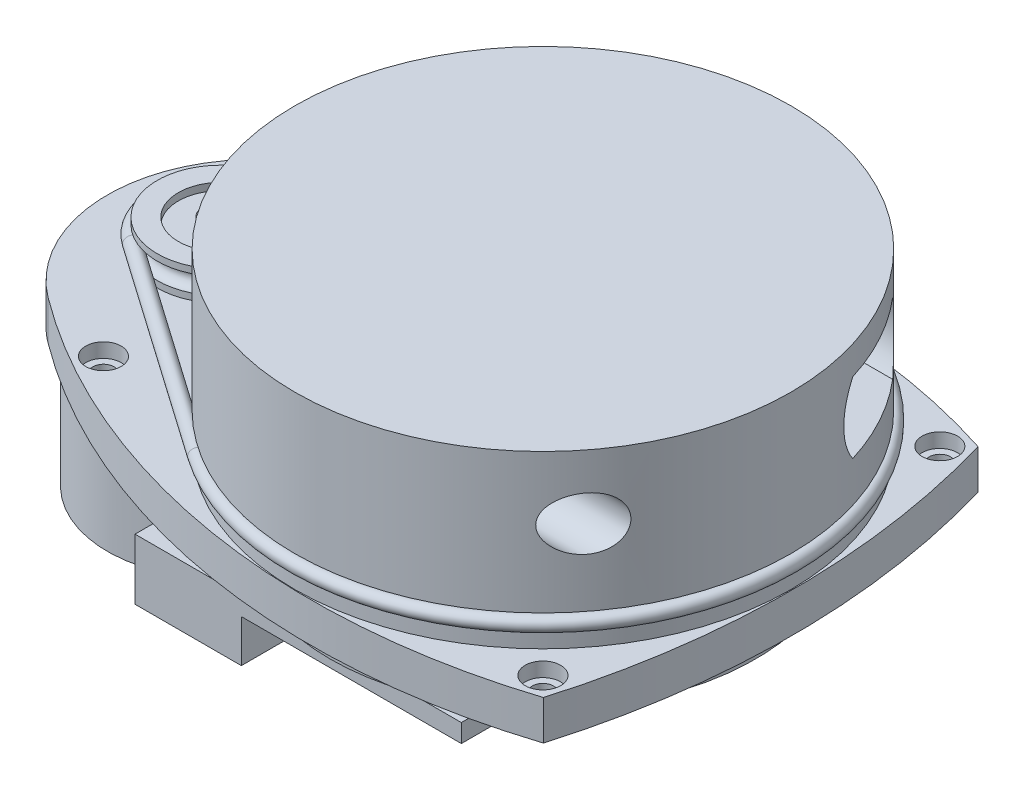
from build123d import *

# Parameters (mm, degrees)
SKETCH1_R           = 1.5
BOSS_EXTRUDE1_DEPTH = 5.57
SKETCH17_R          = 2.5
CUT_EXTRUDE3_DEPTH  = 2.03
SKETCH3_R           = 30
BOSS_EXTRUDE2_DEPTH = 5.43
SKETCH6_W           = 46.04
SKETCH6_H           = 57.01
BOSS_EXTRUDE3_DEPTH = 2.57
SKETCH7_W           = 15
SKETCH7_H           = 57.01
BOSS_EXTRUDE4_DEPTH = 6
CUT_EXTRUDE1_DEPTH  = 5.43
SKETCH9_R           = 16
BOSS_EXTRUDE5_DEPTH = 22
SKETCH10_R          = 0.42
BOSS_EXTRUDE6_DEPTH = 2.9
SKETCH14_R          = 2.5
CUT_EXTRUDE2_DEPTH  = 5.57
SKETCH18_R          = 3.75
CUT_EXTRUDE4_DEPTH  = 24
SKETCH21_R          = 1


with BuildPart() as part:
    # Sketch1 → Boss-Extrude1 (new body)
    with BuildSketch(Plane(origin=(0, 0, 0), x_dir=(1, 0, 0), z_dir=(0, 1, 0))):
        with BuildLine():
            ThreePointArc((-53.025360678, 16.771160637), (-61.44, 0), (-53.025360678, -16.771160637))
            ThreePointArc((-53.025360678, -16.771160637), (-12.835995869, -33.882994203), (30.725545893, -30.659336164))
            ThreePointArc((30.725545893, -30.659336164), (35.14, 0), (30.725545893, 30.659336164))
            ThreePointArc((30.725545893, 30.659336164), (-12.835995869, 33.882994203), (-53.025360678, 16.771160637))
        make_face()
        with Locations((28, -28)):
            Circle(SKETCH1_R, mode=Mode.SUBTRACT)
        with Locations((-42, -20)):
            Circle(SKETCH1_R, mode=Mode.SUBTRACT)
        with Locations((-42, 20)):
            Circle(SKETCH1_R, mode=Mode.SUBTRACT)
        with Locations((28, 28)):
            Circle(SKETCH1_R, mode=Mode.SUBTRACT)
    extrude(amount=BOSS_EXTRUDE1_DEPTH)

    # Sketch17 → Cut-Extrude3 (cut)
    with BuildSketch(Plane(origin=(0, 5.57, 0), x_dir=(1, 0, 0), z_dir=(0, 1, 0))):
        with Locations((-42, 20)):
            Circle(SKETCH17_R)
        with Locations((28, 28)):
            Circle(SKETCH17_R)
        with Locations((28, -28)):
            Circle(SKETCH17_R)
        with Locations((-42, -20)):
            Circle(SKETCH17_R)
    extrude(amount=-CUT_EXTRUDE3_DEPTH, mode=Mode.SUBTRACT)

    # Sketch3 → Boss-Extrude2 (add)
    with BuildSketch(Plane(origin=(0, 0, 0), x_dir=(-1, 0, 0), z_dir=(0, -1, 0))):
        Circle(SKETCH3_R)
    extrude(amount=BOSS_EXTRUDE2_DEPTH)

    # Sketch6 → Boss-Extrude3 (add)
    with BuildSketch(Plane(origin=(0, -5.43, 0), x_dir=(-1, 0, 0), z_dir=(0, -1, 0))):
        with Locations((6.02, 0)):
            Rectangle(SKETCH6_W, SKETCH6_H)
    extrude(amount=BOSS_EXTRUDE3_DEPTH)

    # Sketch7 → Boss-Extrude4 (add)
    with BuildSketch(Plane.XZ.offset(8)):
        with Locations((-21.54, 0)):
            Rectangle(SKETCH7_W, SKETCH7_H)
    extrude(amount=BOSS_EXTRUDE4_DEPTH)

    # Sketch8 → Cut-Extrude1 (cut)
    with BuildSketch(Plane.XZ):
        with BuildLine():
            ThreePointArc((-29.569080106, 5.066507841), (-30, 0), (-29.569080106, -5.066507841))
            ThreePointArc((-29.569080106, -5.066507841), (-28.78, 0), (-29.569080106, 5.066507841))
        make_face()
    extrude(amount=CUT_EXTRUDE1_DEPTH, mode=Mode.SUBTRACT)

    # Sketch9 → Boss-Extrude5 (add)
    with BuildSketch(Plane.XZ):
        with Locations((-45.44, 0)):
            Circle(SKETCH9_R)
    extrude(amount=BOSS_EXTRUDE5_DEPTH)

    # Sketch10 → Boss-Extrude6 (add)
    with BuildSketch(Plane(origin=(0, 5.57, 0), x_dir=(1, 0, 0), z_dir=(0, 1, 0))):
        with Locations((-45.44, 0)):
            Circle(SKETCH10_R)
    extrude(amount=BOSS_EXTRUDE6_DEPTH)

    # Sketch14 → Cut-Extrude2 (cut)
    with BuildSketch(Plane(origin=(0, 5.57, 0), x_dir=(1, 0, 0), z_dir=(0, 1, 0))):
        Circle(SKETCH14_R)
    extrude(amount=-CUT_EXTRUDE2_DEPTH, mode=Mode.SUBTRACT)


with BuildPart() as body_2:
    # Sketch13 → Revolve1 (revolve)
    with BuildSketch(Plane.XY):
        with BuildLine():
            Line((-45.02, 5.57), (-45.02, 10.86))
            Line((-45.02, 10.86), (-42.94, 10.86))
            Line((-42.94, 10.86), (-42.94, 9.84))
            Line((-42.94, 9.84), (-39.45, 9.84))
            Line((-39.45, 9.84), (-39.45, 10.86))
            Line((-39.45, 10.86), (-36.47, 10.86))
            Line((-36.47, 10.86), (-36.47, 9.95))
            ThreePointArc((-36.47, 9.95), (-37.655, 8.765), (-36.47, 7.58))
            Line((-36.47, 7.58), (-36.47, 6.67))
            Line((-36.47, 6.67), (-39.45, 6.67))
            Line((-39.45, 6.67), (-39.45, 7.69))
            Line((-39.45, 7.69), (-42.94, 7.69))
            Line((-42.94, 7.69), (-42.94, 5.57))
            Line((-42.94, 5.57), (-45.02, 5.57))
        make_face()
    revolve(axis=Axis((-45.44, 5.57, 0), (0, 1, 0)))


with BuildPart() as body_3:
    # Sketch16 → Revolve2 (revolve)
    with BuildSketch(Plane.XY):
        with BuildLine():
            Line((0, 29.68), (0, 10.57))
            Line((0, 10.57), (-2.5, 10.57))
            Line((-2.5, 10.57), (-2.5, 5.57))
            Line((-2.5, 5.57), (-35, 5.57))
            Line((-35, 5.57), (-35, 7.58))
            ThreePointArc((-35, 7.58), (-33.815, 8.765), (-35, 9.95))
            Line((-35, 9.95), (-35, 29.68))
            Line((-35, 29.68), (0, 29.68))
        make_face()
    revolve(axis=Axis((0, 5.57, 0), (0, 1, 0)))

    # Sketch18 → Cut-Extrude4 (cut)
    with BuildSketch(Plane(origin=(35, 0, 0), x_dir=(0, 0, -1), z_dir=(1, 0, 0))):
        with Locations((-21.5, 20.68)):
            Circle(SKETCH18_R)
        with BuildLine():
            Line((22.744997998, 25.68), (10.255002002, 25.68))
            ThreePointArc((10.255002002, 25.68), (8.5, 20.68), (10.255002002, 15.68))
            Line((10.255002002, 15.68), (22.744997998, 15.68))
            ThreePointArc((22.744997998, 15.68), (24.5, 20.68), (22.744997998, 25.68))
        make_face()
    extrude(amount=-CUT_EXTRUDE4_DEPTH, mode=Mode.SUBTRACT)


with BuildPart() as body_4:
    # Sweep1: sweep along a path in Sketch19
    with BuildLine(Plane(origin=(0, 8.765, 0), x_dir=(1, 0, 0), z_dir=(0, 1, 0))) as sweep1_path:
        Line((-50.578404489, 7.35239412), (-20.049515845, 28.688271373))
        ThreePointArc((-20.049515845, 28.688271373), (35, 0), (-20.049515845, -28.688271373))
        Line((-20.049515845, -28.688271373), (-50.578404489, -7.35239412))
        ThreePointArc((-50.578404489, -7.35239412), (-54.41, 0), (-50.578404489, 7.35239412))
    # Sketch21 → Sweep1 (sweep)
    with BuildSketch(Plane.XY):
        with Locations((-54.41, 8.765)):
            Circle(SKETCH21_R)
    sweep(path=sweep1_path.line)


solid = Compound([part.part, body_2.part, body_3.part, body_4.part])
